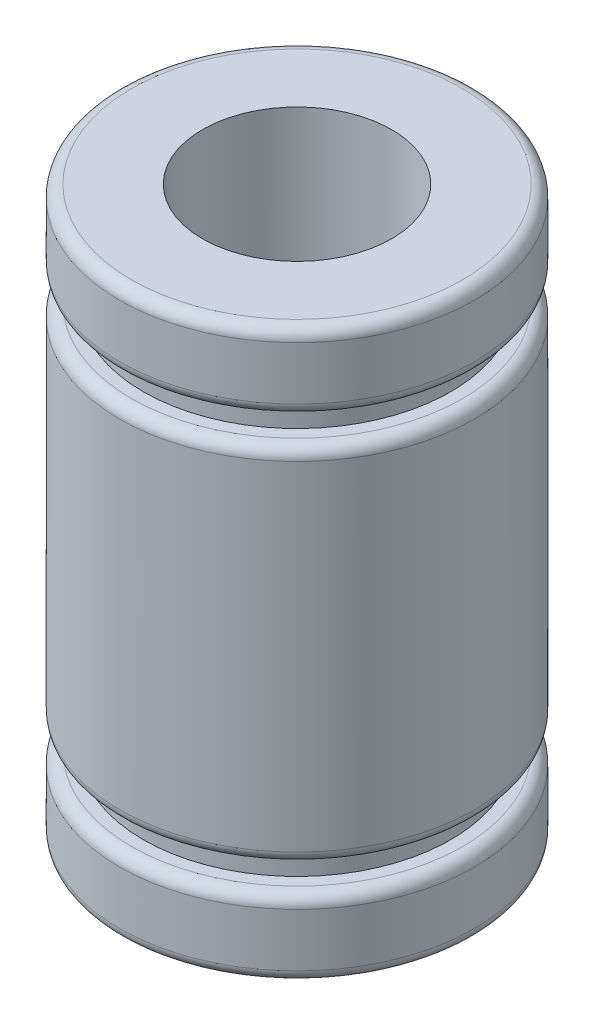
from build123d import *

# Parameters (mm, degrees)
CUT_EXTRUDE2_REACH = 26
SKETCH5_R          = 4
FILLET1_R          = 0.5
FILLET2_R          = 0.5


with BuildPart() as part:
    # Sketch1 → Revolve1 (revolve)
    with BuildSketch(Plane(origin=(0, 0, 0), x_dir=(0, 0, -1), z_dir=(1, 0, 0))):
        Polygon((0, 0), (0, 24), (7.5, 24), (7.5, 20.75), (6.5, 20.75), (6.5, 19.65), (7.5, 19.65), (7.5, 4.35), (6.5, 4.35), (6.5, 3.25), (7.5, 3.25), (7.5, 0), align=None)
    revolve(axis=Axis((0, 0, 0), (0, 1, 0)))

    # Sketch5 → Cut-Extrude2 (cut, up to next)
    with BuildSketch(Plane(origin=(0, 24, 0), x_dir=(1, 0, 0), z_dir=(0, 1, 0)), mode=Mode.PRIVATE) as cut_extrude2_sk1:
        Circle(SKETCH5_R)
    cut_extrude2_tool1 = extrude(cut_extrude2_sk1.sketch, amount=-CUT_EXTRUDE2_REACH, mode=Mode.PRIVATE) & part.part
    add(cut_extrude2_tool1.solids().sort_by_distance((0, 24, 0))[0], mode=Mode.SUBTRACT)

    # Fillet1
    fillet1_edges = [part.edges().sort_by_distance(p)[0] for p in [
        (0, 24, 7.5),
        (0, 0, 7.5),
    ]]
    fillet(fillet1_edges, radius=FILLET1_R)

    # Fillet2
    fillet2_edges = [part.edges().sort_by_distance(p)[0] for p in [
        (0, 4.35, 7.5),
        (0, 19.65, 7.5),
        (0, 20.75, 7.5),
        (0, 3.25, 7.5),
    ]]
    fillet(fillet2_edges, radius=FILLET2_R)


solid = part.part
